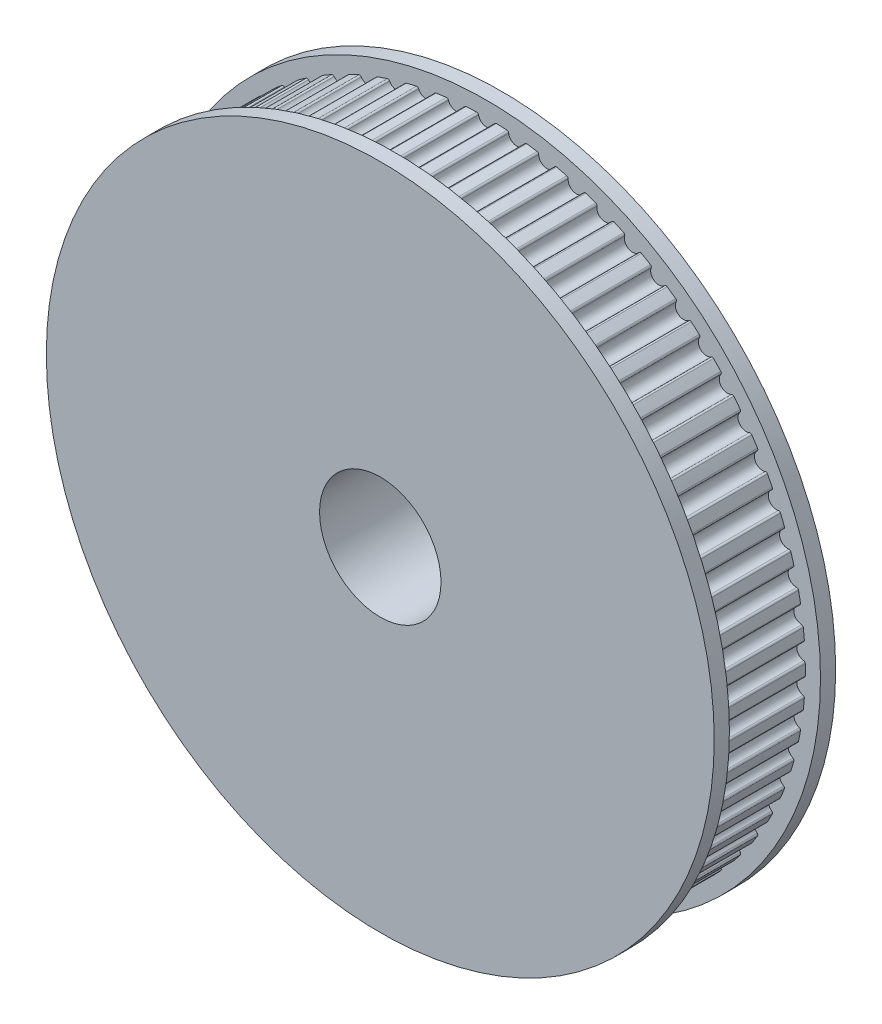
from build123d import *

# Parameters (mm, degrees)
SKETCH1_R           = 4
BOSS_EXTRUDE1_DEPTH = 6
SKETCH2_R           = 22
SKETCH2_R_2         = 4
BOSS_EXTRUDE2_DEPTH = 1
SKETCH3_R           = 22
SKETCH3_R_2         = 4
BOSS_EXTRUDE3_DEPTH = 1


with BuildPart() as part:
    # Sketch1 → Boss-Extrude1 (new body)
    with BuildSketch(Plane.XY):
        with BuildLine():
            ThreePointArc((-0.528729207, 20.890248331), (-0.573745595, 20.963017017), (-0.65501915, 20.989782032))
            ThreePointArc((-0.65501915, 20.989782032), (-0.999220234, 20.976214119), (-1.343152462, 20.957002202))
            ThreePointArc((-1.343152462, 20.957002202), (-1.421513827, 20.922632839), (-1.459409274, 20.845914576))
            ThreePointArc((-1.459409274, 20.845914576), (-1.944846648, 20.367355532), (-2.512079431, 20.745396763))
            ThreePointArc((-2.512079431, 20.745396763), (-2.563809084, 20.813556867), (-2.647258803, 20.832475145))
            ThreePointArc((-2.647258803, 20.832475145), (-2.988611606, 20.786250276), (-3.329160273, 20.734432515))
            ThreePointArc((-3.329160273, 20.734432515), (-3.403899796, 20.692770057), (-3.434331115, 20.612796989))
            ThreePointArc((-3.434331115, 20.612796989), (-3.872080462, 20.090261142), (-4.472679874, 20.41267167))
            ThreePointArc((-4.472679874, 20.41267167), (-4.530654321, 20.475605923), (-4.61552447, 20.486506138))
            ThreePointArc((-4.61552447, 20.486506138), (-4.950937648, 20.408042931), (-5.285018693, 20.324088597))
            ThreePointArc((-5.285018693, 20.324088597), (-5.355459521, 20.275510346), (-5.378151122, 20.193006722))
            ThreePointArc((-5.378151122, 20.193006722), (-5.764248115, 19.631226236), (-6.392775036, 19.89508626))
            ThreePointArc((-6.392775036, 19.89508626), (-6.456469252, 19.952224721), (-6.541991233, 19.955008158))
            ThreePointArc((-6.541991233, 19.955008158), (-6.868427232, 19.845017189), (-7.193015165, 19.729686584))
            ThreePointArc((-7.193015165, 19.729686584), (-7.258519376, 19.674632474), (-7.273265759, 19.590345458))
            ThreePointArc((-7.273265759, 19.590345458), (-7.604213845, 18.994407906), (-8.254976237, 19.197327869))
            ThreePointArc((-8.254976237, 19.197327869), (-8.323813396, 19.248153082), (-8.40921271, 19.242794534))
            ThreePointArc((-8.40921271, 19.242794534), (-8.723715275, 19.102271899), (-9.035870578, 18.956609475))
            ThreePointArc((-9.035870578, 18.956609475), (-9.095844955, 18.895578082), (-9.102512575, 18.810270992))
            ThreePointArc((-9.102512575, 18.810270992), (-9.375314637, 18.185573276), (-10.042419095, 18.325715503))
            ThreePointArc((-10.042419095, 18.325715503), (-10.115775798, 18.369767188), (-10.200279055, 18.356315183))
            ThreePointArc((-10.200279055, 18.356315183), (-10.500000002, 18.186533476), (-10.796895748, 18.011858375))
            ThreePointArc((-10.796895748, 18.011858375), (-10.850797154, 17.94540241), (-10.849325627, 17.859847799))
            ThreePointArc((-10.849325627, 17.859847799), (-11.061511127, 17.212047278), (-11.73891625, 17.28814262))
            ThreePointArc((-11.73891625, 17.28814262), (-11.816128168, 17.325021837), (-11.898970093, 17.3035982))
            ThreePointArc((-11.898970093, 17.3035982), (-12.181195103, 17.106094989), (-12.460142558, 16.903989096))
            ThreePointArc((-12.460142558, 16.903989096), (-12.507482853, 16.832710395), (-12.497885507, 16.747683059))
            ThreePointArc((-12.497885507, 16.747683059), (-12.64753286, 16.082646315), (-13.329103963, 16.094005641))
            ThreePointArc((-13.329103963, 16.094005641), (-13.409471851, 16.123378406), (-13.489902215, 16.094177151))
            ThreePointArc((-13.489902215, 16.094177151), (-13.752075415, 15.870741058), (-14.010548388, 15.643034674))
            ThreePointArc((-14.010548388, 15.643034674), (-14.050898851, 15.567578747), (-14.0332626, 15.483848708))
            ThreePointArc((-14.0332626, 15.483848708), (-14.119016577, 14.807598416), (-14.798581245, 14.754118854))
            ThreePointArc((-14.798581245, 14.754118854), (-14.88137728, 14.775719164), (-14.958667694, 14.739004742))
            ThreePointArc((-14.958667694, 14.739004742), (-15.198414802, 14.491659237), (-15.434072522, 14.240414508))
            ThreePointArc((-15.434072522, 14.240414508), (-15.467067733, 14.161464696), (-15.441552294, 14.079790225))
            ThreePointArc((-15.441552294, 14.079790225), (-15.462636293, 13.398450613), (-16.134040285, 13.280616482))
            ThreePointArc((-16.134040285, 13.280616482), (-16.218514653, 13.29424872), (-16.291965162, 13.250353623))
            ThreePointArc((-16.291965162, 13.250353623), (-16.507114992, 12.981338707), (-16.717823305, 12.708830943))
            ThreePointArc((-16.717823305, 12.708830943), (-16.743164454, 12.627102227), (-16.7100009, 12.548222981))
            ThreePointArc((-16.7100009, 12.548222981), (-16.666223981, 11.867964366), (-17.323386957, 11.68684279))
            ThreePointArc((-17.323386957, 11.68684279), (-17.408774645, 11.692383502), (-17.47772007, 11.641705251))
            ThreePointArc((-17.47772007, 11.641705251), (-17.666324192, 11.353457163), (-17.850174891, 11.062154236))
            ThreePointArc((-17.850174891, 11.062154236), (-17.867632486, 10.978386765), (-17.827121149, 10.903017087))
            ThreePointArc((-17.827121149, 10.903017087), (-17.718879764, 10.229999996), (-18.355850354, 9.987231241))
            ThreePointArc((-18.355850354, 9.987231241), (-18.441378078, 9.984630248), (-18.505194039, 9.927627792))
            ThreePointArc((-18.505194039, 9.927627792), (-18.665544424, 9.622756953), (-18.82087253, 9.315296948))
            ThreePointArc((-18.82087253, 9.315296948), (-18.83028847, 9.230249333), (-18.782796229, 9.159071782))
            ThreePointArc((-18.782796229, 9.159071782), (-18.611070627, 8.499391162), (-19.222080328, 8.197173778))
            ThreePointArc((-19.222080328, 8.197173778), (-19.306973536, 8.186454636), (-19.365082105, 8.123644199))
            ThreePointArc((-19.365082105, 8.123644199), (-19.495726595, 7.804911565), (-19.621125432, 7.484078888))
            ThreePointArc((-19.621125432, 7.484078888), (-19.622414447, 7.398521333), (-19.568371398, 7.332180504))
            ThreePointArc((-19.568371398, 7.332180504), (-19.334716753, 6.691810526), (-19.914232166, 6.332881441))
            ThreePointArc((-19.914232166, 6.332881441), (-19.997722052, 6.314141223), (-20.049596989, 6.246091626))
            ThreePointArc((-20.049596989, 6.246091626), (-20.149352448, 5.91638369), (-20.243686384, 5.585083851))
            ThreePointArc((-20.243686384, 5.585083851), (-20.2368368, 5.499791179), (-20.176732365, 5.438887864))
            ThreePointArc((-20.176732365, 5.438887864), (-19.88326469, 4.823627817), (-20.426037634, 4.411237548))
            ThreePointArc((-20.426037634, 4.411237548), (-20.5073681, 4.38464597), (-20.552539618, 4.31197348))
            ThreePointArc((-20.552539618, 4.31197348), (-20.620502645, 3.974276128), (-20.682917378, 3.63550943))
            ThreePointArc((-20.682917378, 3.63550943), (-20.667991224, 3.551254063), (-20.602369719, 3.496339813))
            ThreePointArc((-20.602369719, 3.496339813), (-20.251746703, 2.911761587), (-20.752861742, 2.449644806))
            ThreePointArc((-20.752861742, 2.449644806), (-20.831296247, 2.415442683), (-20.869355266, 2.338805435))
            ThreePointArc((-20.869355266, 2.338805435), (-20.904910376, 1.996176906), (-20.934840668, 1.653011272))
            ThreePointArc((-20.934840668, 1.653011272), (-20.91197312, 1.570556241), (-20.841428823, 1.522128368))
            ThreePointArc((-20.841428823, 1.522128368), (-20.436825762, 0.973525994), (-20.89174472, 0.4658677))
            ThreePointArc((-20.89174472, 0.4658677), (-20.966572949, 0.424364774), (-20.9971748, 0.344456805))
            ThreePointArc((-20.9971748, 0.344456805), (-21.000000002, -4e-09), (-20.9971748, -0.344456812))
            ThreePointArc((-20.9971748, -0.344456812), (-20.966572949, -0.424364781), (-20.89174472, -0.465867708))
            ThreePointArc((-20.89174472, -0.465867708), (-20.436825762, -0.973526002), (-20.841428823, -1.522128376))
            ThreePointArc((-20.841428823, -1.522128376), (-20.91197312, -1.570556249), (-20.934840668, -1.653011279))
            ThreePointArc((-20.934840668, -1.653011279), (-20.904910376, -1.996176913), (-20.869355266, -2.338805442))
            ThreePointArc((-20.869355266, -2.338805442), (-20.831296247, -2.415442691), (-20.752861742, -2.449644813))
            ThreePointArc((-20.752861742, -2.449644813), (-20.251746703, -2.911761595), (-20.602369719, -3.496339821))
            ThreePointArc((-20.602369719, -3.496339821), (-20.667991224, -3.551254071), (-20.682917378, -3.635509437))
            ThreePointArc((-20.682917378, -3.635509437), (-20.620502645, -3.974276135), (-20.552539618, -4.311973488))
            ThreePointArc((-20.552539618, -4.311973488), (-20.5073681, -4.384645977), (-20.426037634, -4.411237556))
            ThreePointArc((-20.426037634, -4.411237556), (-19.88326469, -4.823627824), (-20.176732365, -5.438887872))
            ThreePointArc((-20.176732365, -5.438887872), (-20.2368368, -5.499791186), (-20.243686384, -5.585083859))
            ThreePointArc((-20.243686384, -5.585083859), (-20.149352448, -5.916383697), (-20.049596989, -6.246091634))
            ThreePointArc((-20.049596989, -6.246091634), (-19.997722052, -6.314141231), (-19.914232166, -6.332881448))
            ThreePointArc((-19.914232166, -6.332881448), (-19.334716753, -6.691810533), (-19.568371398, -7.332180511))
            ThreePointArc((-19.568371398, -7.332180511), (-19.622414447, -7.398521341), (-19.621125432, -7.484078896))
            ThreePointArc((-19.621125432, -7.484078896), (-19.495726595, -7.804911573), (-19.365082105, -8.123644207))
            ThreePointArc((-19.365082105, -8.123644207), (-19.306973536, -8.186454643), (-19.222080328, -8.197173786))
            ThreePointArc((-19.222080328, -8.197173786), (-18.611070627, -8.49939117), (-18.782796229, -9.159071789))
            ThreePointArc((-18.782796229, -9.159071789), (-18.83028847, -9.23024934), (-18.82087253, -9.315296956))
            ThreePointArc((-18.82087253, -9.315296956), (-18.665544424, -9.62275696), (-18.505194039, -9.9276278))
            ThreePointArc((-18.505194039, -9.9276278), (-18.441378078, -9.984630255), (-18.355850354, -9.987231248))
            ThreePointArc((-18.355850354, -9.987231248), (-17.718879764, -10.230000004), (-17.827121149, -10.903017094))
            ThreePointArc((-17.827121149, -10.903017094), (-17.867632486, -10.978386773), (-17.850174891, -11.062154244))
            ThreePointArc((-17.850174891, -11.062154244), (-17.666324192, -11.35345717), (-17.47772007, -11.641705258))
            ThreePointArc((-17.47772007, -11.641705258), (-17.408774645, -11.692383509), (-17.323386957, -11.686842798))
            ThreePointArc((-17.323386957, -11.686842798), (-16.666223981, -11.867964374), (-16.7100009, -12.548222989))
            ThreePointArc((-16.7100009, -12.548222989), (-16.743164454, -12.627102235), (-16.717823305, -12.70883095))
            ThreePointArc((-16.717823305, -12.70883095), (-16.507114992, -12.981338714), (-16.291965162, -13.250353631))
            ThreePointArc((-16.291965162, -13.250353631), (-16.218514653, -13.294248728), (-16.134040285, -13.280616489))
            ThreePointArc((-16.134040285, -13.280616489), (-15.462636293, -13.39845062), (-15.441552294, -14.079790232))
            ThreePointArc((-15.441552294, -14.079790232), (-15.467067733, -14.161464703), (-15.434072522, -14.240414515))
            ThreePointArc((-15.434072522, -14.240414515), (-15.198414802, -14.491659245), (-14.958667694, -14.739004749))
            ThreePointArc((-14.958667694, -14.739004749), (-14.88137728, -14.775719171), (-14.798581245, -14.754118861))
            ThreePointArc((-14.798581245, -14.754118861), (-14.119016577, -14.807598423), (-14.0332626, -15.483848715))
            ThreePointArc((-14.0332626, -15.483848715), (-14.050898851, -15.567578755), (-14.010548388, -15.643034682))
            ThreePointArc((-14.010548388, -15.643034682), (-13.752075415, -15.870741065), (-13.489902215, -16.094177159))
            ThreePointArc((-13.489902215, -16.094177159), (-13.409471851, -16.123378414), (-13.329103963, -16.094005648))
            ThreePointArc((-13.329103963, -16.094005648), (-12.64753286, -16.082646322), (-12.497885507, -16.747683067))
            ThreePointArc((-12.497885507, -16.747683067), (-12.507482853, -16.832710402), (-12.460142558, -16.903989104))
            ThreePointArc((-12.460142558, -16.903989104), (-12.181195103, -17.106094997), (-11.898970093, -17.303598207))
            ThreePointArc((-11.898970093, -17.303598207), (-11.816128168, -17.325021845), (-11.73891625, -17.288142628))
            ThreePointArc((-11.73891625, -17.288142628), (-11.061511127, -17.212047285), (-10.849325627, -17.859847807))
            ThreePointArc((-10.849325627, -17.859847807), (-10.850797154, -17.945402418), (-10.796895748, -18.011858382))
            ThreePointArc((-10.796895748, -18.011858382), (-10.500000002, -18.186533483), (-10.200279055, -18.356315191))
            ThreePointArc((-10.200279055, -18.356315191), (-10.115775798, -18.369767195), (-10.042419095, -18.325715511))
            ThreePointArc((-10.042419095, -18.325715511), (-9.375314637, -18.185573283), (-9.102512575, -18.810271))
            ThreePointArc((-9.102512575, -18.810271), (-9.095844955, -18.89557809), (-9.035870578, -18.956609483))
            ThreePointArc((-9.035870578, -18.956609483), (-8.723715275, -19.102271906), (-8.40921271, -19.242794542))
            ThreePointArc((-8.40921271, -19.242794542), (-8.323813396, -19.248153089), (-8.254976237, -19.197327876))
            ThreePointArc((-8.254976237, -19.197327876), (-7.604213845, -18.994407913), (-7.273265759, -19.590345465))
            ThreePointArc((-7.273265759, -19.590345465), (-7.258519376, -19.674632481), (-7.193015165, -19.729686592))
            ThreePointArc((-7.193015165, -19.729686592), (-6.868427232, -19.845017197), (-6.541991233, -19.955008166))
            ThreePointArc((-6.541991233, -19.955008166), (-6.456469252, -19.952224728), (-6.392775036, -19.895086268))
            ThreePointArc((-6.392775036, -19.895086268), (-5.764248115, -19.631226244), (-5.378151122, -20.193006729))
            ThreePointArc((-5.378151122, -20.193006729), (-5.355459521, -20.275510354), (-5.285018693, -20.324088604))
            ThreePointArc((-5.285018693, -20.324088604), (-4.950937648, -20.408042939), (-4.61552447, -20.486506145))
            ThreePointArc((-4.61552447, -20.486506145), (-4.530654321, -20.47560593), (-4.472679874, -20.412671677))
            ThreePointArc((-4.472679874, -20.412671677), (-3.872080462, -20.09026115), (-3.434331115, -20.612796997))
            ThreePointArc((-3.434331115, -20.612796997), (-3.403899796, -20.692770065), (-3.329160273, -20.734432523))
            ThreePointArc((-3.329160273, -20.734432523), (-2.988611606, -20.786250283), (-2.647258803, -20.832475153))
            ThreePointArc((-2.647258803, -20.832475153), (-2.563809084, -20.813556874), (-2.512079431, -20.745396771))
            ThreePointArc((-2.512079431, -20.745396771), (-1.944846648, -20.36735554), (-1.459409274, -20.845914583))
            ThreePointArc((-1.459409274, -20.845914583), (-1.421513827, -20.922632846), (-1.343152462, -20.95700221))
            ThreePointArc((-1.343152462, -20.95700221), (-0.999220234, -20.976214127), (-0.65501915, -20.98978204))
            ThreePointArc((-0.65501915, -20.98978204), (-0.573745595, -20.963017024), (-0.528729207, -20.890248339))
            ThreePointArc((-0.528729207, -20.890248339), (-2e-09, -20.460000004), (0.528729203, -20.890248339))
            ThreePointArc((0.528729203, -20.890248339), (0.573745591, -20.963017024), (0.655019146, -20.98978204))
            ThreePointArc((0.655019146, -20.98978204), (0.99922023, -20.976214127), (1.343152457, -20.95700221))
            ThreePointArc((1.343152457, -20.95700221), (1.421513823, -20.922632846), (1.45940927, -20.845914583))
            ThreePointArc((1.45940927, -20.845914583), (1.944846644, -20.36735554), (2.512079426, -20.745396771))
            ThreePointArc((2.512079426, -20.745396771), (2.56380908, -20.813556874), (2.647258799, -20.832475153))
            ThreePointArc((2.647258799, -20.832475153), (2.988611602, -20.786250283), (3.329160268, -20.734432523))
            ThreePointArc((3.329160268, -20.734432523), (3.403899792, -20.692770065), (3.434331111, -20.612796997))
            ThreePointArc((3.434331111, -20.612796997), (3.872080457, -20.09026115), (4.47267987, -20.412671677))
            ThreePointArc((4.47267987, -20.412671677), (4.530654317, -20.47560593), (4.615524466, -20.486506145))
            ThreePointArc((4.615524466, -20.486506145), (4.950937644, -20.408042939), (5.285018688, -20.324088604))
            ThreePointArc((5.285018688, -20.324088604), (5.355459517, -20.275510354), (5.378151117, -20.193006729))
            ThreePointArc((5.378151117, -20.193006729), (5.764248111, -19.631226244), (6.392775031, -19.895086268))
            ThreePointArc((6.392775031, -19.895086268), (6.456469247, -19.952224728), (6.541991228, -19.955008166))
            ThreePointArc((6.541991228, -19.955008166), (6.868427228, -19.845017197), (7.193015161, -19.729686592))
            ThreePointArc((7.193015161, -19.729686592), (7.258519372, -19.674632481), (7.273265754, -19.590345465))
            ThreePointArc((7.273265754, -19.590345465), (7.604213841, -18.994407913), (8.254976232, -19.197327876))
            ThreePointArc((8.254976232, -19.197327876), (8.323813392, -19.248153089), (8.409212706, -19.242794542))
            ThreePointArc((8.409212706, -19.242794542), (8.723715271, -19.102271906), (9.035870574, -18.956609483))
            ThreePointArc((9.035870574, -18.956609483), (9.095844951, -18.89557809), (9.102512571, -18.810271))
            ThreePointArc((9.102512571, -18.810271), (9.375314632, -18.185573283), (10.042419091, -18.325715511))
            ThreePointArc((10.042419091, -18.325715511), (10.115775794, -18.369767195), (10.20027905, -18.356315191))
            ThreePointArc((10.20027905, -18.356315191), (10.499999998, -18.186533483), (10.796895744, -18.011858382))
            ThreePointArc((10.796895744, -18.011858382), (10.850797149, -17.945402418), (10.849325623, -17.859847807))
            ThreePointArc((10.849325623, -17.859847807), (11.061511123, -17.212047285), (11.738916246, -17.288142628))
            ThreePointArc((11.738916246, -17.288142628), (11.816128163, -17.325021845), (11.898970088, -17.303598207))
            ThreePointArc((11.898970088, -17.303598207), (12.181195099, -17.106094997), (12.460142554, -16.903989104))
            ThreePointArc((12.460142554, -16.903989104), (12.507482849, -16.832710402), (12.497885503, -16.747683067))
            ThreePointArc((12.497885503, -16.747683067), (12.647532856, -16.082646322), (13.329103958, -16.094005648))
            ThreePointArc((13.329103958, -16.094005648), (13.409471846, -16.123378414), (13.489902211, -16.094177159))
            ThreePointArc((13.489902211, -16.094177159), (13.752075411, -15.870741065), (14.010548383, -15.643034682))
            ThreePointArc((14.010548383, -15.643034682), (14.050898846, -15.567578755), (14.033262596, -15.483848715))
            ThreePointArc((14.033262596, -15.483848715), (14.119016573, -14.807598423), (14.798581241, -14.754118861))
            ThreePointArc((14.798581241, -14.754118861), (14.881377276, -14.775719171), (14.958667689, -14.739004749))
            ThreePointArc((14.958667689, -14.739004749), (15.198414798, -14.491659245), (15.434072517, -14.240414515))
            ThreePointArc((15.434072517, -14.240414515), (15.467067728, -14.161464703), (15.44155229, -14.079790232))
            ThreePointArc((15.44155229, -14.079790232), (15.462636289, -13.39845062), (16.13404028, -13.280616489))
            ThreePointArc((16.13404028, -13.280616489), (16.218514649, -13.294248728), (16.291965157, -13.250353631))
            ThreePointArc((16.291965157, -13.250353631), (16.507114987, -12.981338714), (16.7178233, -12.70883095))
            ThreePointArc((16.7178233, -12.70883095), (16.74316445, -12.627102235), (16.710000895, -12.548222989))
            ThreePointArc((16.710000895, -12.548222989), (16.666223977, -11.867964374), (17.323386953, -11.686842798))
            ThreePointArc((17.323386953, -11.686842798), (17.408774641, -11.692383509), (17.477720066, -11.641705258))
            ThreePointArc((17.477720066, -11.641705258), (17.666324187, -11.35345717), (17.850174887, -11.062154244))
            ThreePointArc((17.850174887, -11.062154244), (17.867632481, -10.978386773), (17.827121145, -10.903017094))
            ThreePointArc((17.827121145, -10.903017094), (17.718879759, -10.230000004), (18.35585035, -9.987231248))
            ThreePointArc((18.35585035, -9.987231248), (18.441378074, -9.984630255), (18.505194035, -9.9276278))
            ThreePointArc((18.505194035, -9.9276278), (18.66554442, -9.62275696), (18.820872525, -9.315296956))
            ThreePointArc((18.820872525, -9.315296956), (18.830288466, -9.23024934), (18.782796225, -9.159071789))
            ThreePointArc((18.782796225, -9.159071789), (18.611070623, -8.49939117), (19.222080324, -8.197173786))
            ThreePointArc((19.222080324, -8.197173786), (19.306973532, -8.186454643), (19.365082101, -8.123644207))
            ThreePointArc((19.365082101, -8.123644207), (19.495726591, -7.804911573), (19.621125428, -7.484078896))
            ThreePointArc((19.621125428, -7.484078896), (19.622414443, -7.398521341), (19.568371394, -7.332180511))
            ThreePointArc((19.568371394, -7.332180511), (19.334716749, -6.691810533), (19.914232162, -6.332881448))
            ThreePointArc((19.914232162, -6.332881448), (19.997722048, -6.314141231), (20.049596985, -6.246091634))
            ThreePointArc((20.049596985, -6.246091634), (20.149352444, -5.916383697), (20.24368638, -5.585083859))
            ThreePointArc((20.24368638, -5.585083859), (20.236836795, -5.499791186), (20.176732361, -5.438887872))
            ThreePointArc((20.176732361, -5.438887872), (19.883264686, -4.823627824), (20.42603763, -4.411237556))
            ThreePointArc((20.42603763, -4.411237556), (20.507368096, -4.384645977), (20.552539614, -4.311973488))
            ThreePointArc((20.552539614, -4.311973488), (20.62050264, -3.974276135), (20.682917373, -3.635509437))
            ThreePointArc((20.682917373, -3.635509437), (20.66799122, -3.551254071), (20.602369715, -3.496339821))
            ThreePointArc((20.602369715, -3.496339821), (20.251746699, -2.911761595), (20.752861737, -2.449644813))
            ThreePointArc((20.752861737, -2.449644813), (20.831296243, -2.415442691), (20.869355262, -2.338805442))
            ThreePointArc((20.869355262, -2.338805442), (20.904910372, -1.996176913), (20.934840664, -1.653011279))
            ThreePointArc((20.934840664, -1.653011279), (20.911973116, -1.570556249), (20.841428819, -1.522128376))
            ThreePointArc((20.841428819, -1.522128376), (20.436825758, -0.973526002), (20.891744716, -0.465867708))
            ThreePointArc((20.891744716, -0.465867708), (20.966572945, -0.424364781), (20.997174796, -0.344456812))
            ThreePointArc((20.997174796, -0.344456812), (20.999999998, -4e-09), (20.997174796, 0.344456805))
            ThreePointArc((20.997174796, 0.344456805), (20.966572945, 0.424364774), (20.891744716, 0.4658677))
            ThreePointArc((20.891744716, 0.4658677), (20.436825758, 0.973525994), (20.841428819, 1.522128368))
            ThreePointArc((20.841428819, 1.522128368), (20.911973116, 1.570556241), (20.934840664, 1.653011272))
            ThreePointArc((20.934840664, 1.653011272), (20.904910372, 1.996176906), (20.869355262, 2.338805435))
            ThreePointArc((20.869355262, 2.338805435), (20.831296243, 2.415442683), (20.752861737, 2.449644806))
            ThreePointArc((20.752861737, 2.449644806), (20.251746699, 2.911761587), (20.602369715, 3.496339813))
            ThreePointArc((20.602369715, 3.496339813), (20.66799122, 3.551254063), (20.682917373, 3.63550943))
            ThreePointArc((20.682917373, 3.63550943), (20.62050264, 3.974276128), (20.552539614, 4.31197348))
            ThreePointArc((20.552539614, 4.31197348), (20.507368096, 4.38464597), (20.42603763, 4.411237548))
            ThreePointArc((20.42603763, 4.411237548), (19.883264686, 4.823627817), (20.176732361, 5.438887864))
            ThreePointArc((20.176732361, 5.438887864), (20.236836795, 5.499791179), (20.24368638, 5.585083851))
            ThreePointArc((20.24368638, 5.585083851), (20.149352444, 5.91638369), (20.049596985, 6.246091626))
            ThreePointArc((20.049596985, 6.246091626), (19.997722048, 6.314141223), (19.914232162, 6.332881441))
            ThreePointArc((19.914232162, 6.332881441), (19.334716749, 6.691810526), (19.568371394, 7.332180504))
            ThreePointArc((19.568371394, 7.332180504), (19.622414443, 7.398521333), (19.621125428, 7.484078888))
            ThreePointArc((19.621125428, 7.484078888), (19.495726591, 7.804911565), (19.365082101, 8.123644199))
            ThreePointArc((19.365082101, 8.123644199), (19.306973532, 8.186454636), (19.222080324, 8.197173778))
            ThreePointArc((19.222080324, 8.197173778), (18.611070623, 8.499391162), (18.782796225, 9.159071782))
            ThreePointArc((18.782796225, 9.159071782), (18.830288466, 9.230249333), (18.820872525, 9.315296948))
            ThreePointArc((18.820872525, 9.315296948), (18.66554442, 9.622756953), (18.505194035, 9.927627792))
            ThreePointArc((18.505194035, 9.927627792), (18.441378074, 9.984630248), (18.35585035, 9.987231241))
            ThreePointArc((18.35585035, 9.987231241), (17.718879759, 10.229999996), (17.827121145, 10.903017087))
            ThreePointArc((17.827121145, 10.903017087), (17.867632481, 10.978386765), (17.850174887, 11.062154236))
            ThreePointArc((17.850174887, 11.062154236), (17.666324187, 11.353457163), (17.477720066, 11.641705251))
            ThreePointArc((17.477720066, 11.641705251), (17.408774641, 11.692383502), (17.323386953, 11.68684279))
            ThreePointArc((17.323386953, 11.68684279), (16.666223977, 11.867964366), (16.710000895, 12.548222981))
            ThreePointArc((16.710000895, 12.548222981), (16.74316445, 12.627102227), (16.7178233, 12.708830943))
            ThreePointArc((16.7178233, 12.708830943), (16.507114987, 12.981338707), (16.291965157, 13.250353623))
            ThreePointArc((16.291965157, 13.250353623), (16.218514649, 13.29424872), (16.13404028, 13.280616482))
            ThreePointArc((16.13404028, 13.280616482), (15.462636289, 13.398450613), (15.44155229, 14.079790225))
            ThreePointArc((15.44155229, 14.079790225), (15.467067728, 14.161464696), (15.434072517, 14.240414508))
            ThreePointArc((15.434072517, 14.240414508), (15.198414798, 14.491659237), (14.958667689, 14.739004742))
            ThreePointArc((14.958667689, 14.739004742), (14.881377276, 14.775719164), (14.798581241, 14.754118854))
            ThreePointArc((14.798581241, 14.754118854), (14.119016573, 14.807598416), (14.033262596, 15.483848708))
            ThreePointArc((14.033262596, 15.483848708), (14.050898846, 15.567578747), (14.010548383, 15.643034674))
            ThreePointArc((14.010548383, 15.643034674), (13.752075411, 15.870741058), (13.489902211, 16.094177151))
            ThreePointArc((13.489902211, 16.094177151), (13.409471846, 16.123378406), (13.329103958, 16.094005641))
            ThreePointArc((13.329103958, 16.094005641), (12.647532856, 16.082646315), (12.497885503, 16.747683059))
            ThreePointArc((12.497885503, 16.747683059), (12.507482849, 16.832710395), (12.460142554, 16.903989096))
            ThreePointArc((12.460142554, 16.903989096), (12.181195099, 17.106094989), (11.898970088, 17.3035982))
            ThreePointArc((11.898970088, 17.3035982), (11.816128163, 17.325021837), (11.738916246, 17.28814262))
            ThreePointArc((11.738916246, 17.28814262), (11.061511123, 17.212047278), (10.849325623, 17.859847799))
            ThreePointArc((10.849325623, 17.859847799), (10.850797149, 17.94540241), (10.796895744, 18.011858375))
            ThreePointArc((10.796895744, 18.011858375), (10.499999998, 18.186533476), (10.20027905, 18.356315183))
            ThreePointArc((10.20027905, 18.356315183), (10.115775794, 18.369767188), (10.042419091, 18.325715503))
            ThreePointArc((10.042419091, 18.325715503), (9.375314632, 18.185573276), (9.102512571, 18.810270992))
            ThreePointArc((9.102512571, 18.810270992), (9.095844951, 18.895578082), (9.035870574, 18.956609475))
            ThreePointArc((9.035870574, 18.956609475), (8.723715271, 19.102271899), (8.409212706, 19.242794534))
            ThreePointArc((8.409212706, 19.242794534), (8.323813392, 19.248153082), (8.254976232, 19.197327869))
            ThreePointArc((8.254976232, 19.197327869), (7.604213841, 18.994407906), (7.273265754, 19.590345458))
            ThreePointArc((7.273265754, 19.590345458), (7.258519372, 19.674632474), (7.193015161, 19.729686584))
            ThreePointArc((7.193015161, 19.729686584), (6.868427228, 19.845017189), (6.541991228, 19.955008158))
            ThreePointArc((6.541991228, 19.955008158), (6.456469247, 19.952224721), (6.392775031, 19.89508626))
            ThreePointArc((6.392775031, 19.89508626), (5.764248111, 19.631226236), (5.378151117, 20.193006722))
            ThreePointArc((5.378151117, 20.193006722), (5.355459517, 20.275510346), (5.285018688, 20.324088597))
            ThreePointArc((5.285018688, 20.324088597), (4.950937644, 20.408042931), (4.615524466, 20.486506138))
            ThreePointArc((4.615524466, 20.486506138), (4.530654317, 20.475605923), (4.47267987, 20.41267167))
            ThreePointArc((4.47267987, 20.41267167), (3.872080457, 20.090261142), (3.434331111, 20.612796989))
            ThreePointArc((3.434331111, 20.612796989), (3.403899792, 20.692770057), (3.329160268, 20.734432515))
            ThreePointArc((3.329160268, 20.734432515), (2.988611602, 20.786250276), (2.647258799, 20.832475145))
            ThreePointArc((2.647258799, 20.832475145), (2.56380908, 20.813556867), (2.512079426, 20.745396763))
            ThreePointArc((2.512079426, 20.745396763), (1.944846644, 20.367355532), (1.45940927, 20.845914576))
            ThreePointArc((1.45940927, 20.845914576), (1.421513823, 20.922632839), (1.343152457, 20.957002202))
            ThreePointArc((1.343152457, 20.957002202), (0.99922023, 20.976214119), (0.655019146, 20.989782032))
            ThreePointArc((0.655019146, 20.989782032), (0.573745591, 20.963017017), (0.528729203, 20.890248331))
            ThreePointArc((0.528729203, 20.890248331), (-2e-09, 20.459999996), (-0.528729207, 20.890248331))
        make_face()
        Circle(SKETCH1_R, mode=Mode.SUBTRACT)
    extrude(amount=BOSS_EXTRUDE1_DEPTH)

    # Sketch2 → Boss-Extrude2 (add)
    with BuildSketch(Plane.XY.offset(6)):
        Circle(SKETCH2_R)
        Circle(SKETCH2_R_2, mode=Mode.SUBTRACT)
    extrude(amount=BOSS_EXTRUDE2_DEPTH)

    # Sketch3 → Boss-Extrude3 (add)
    with BuildSketch(Plane(origin=(0, 0, 0), x_dir=(-1, 0, 0), z_dir=(0, 0, -1))):
        Circle(SKETCH3_R)
        Circle(SKETCH3_R_2, mode=Mode.SUBTRACT)
    extrude(amount=BOSS_EXTRUDE3_DEPTH)


solid = part.part
